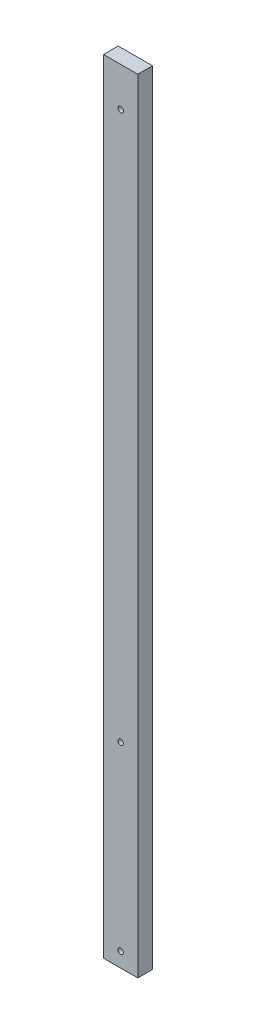
from build123d import *

# Parameters (mm, degrees)
SKETCH1_W               = 88.9
SKETCH1_H               = 38.1
BOSS_EXTRUDE1_DEPTH     = 2032
SKETCH2_R               = 7.14375
CUT_EXTRUDE1_DEPTH      = 1
CUT_EXTRUDE1_DEPTH_BACK = 39.1


with BuildPart() as part:
    # Sketch1 → Boss-Extrude1 (new body)
    with BuildSketch(Plane(origin=(0, 0, 0), x_dir=(1, 0, 0), z_dir=(0, 1, 0))):
        Rectangle(SKETCH1_W, SKETCH1_H)
    extrude(amount=BOSS_EXTRUDE1_DEPTH)

    # Sketch2 → Cut-Extrude1 (cut, two sides)
    with BuildSketch(Plane.XY.offset(19.05)) as cut_extrude1_sk:
        with Locations((0, 38.1)):
            Circle(SKETCH2_R)
        with Locations((0, 508)):
            Circle(SKETCH2_R)
        with Locations((0, 1930.4)):
            Circle(SKETCH2_R)
    extrude(amount=CUT_EXTRUDE1_DEPTH, mode=Mode.SUBTRACT)
    extrude(cut_extrude1_sk.sketch, amount=-CUT_EXTRUDE1_DEPTH_BACK, mode=Mode.SUBTRACT)


solid = part.part
